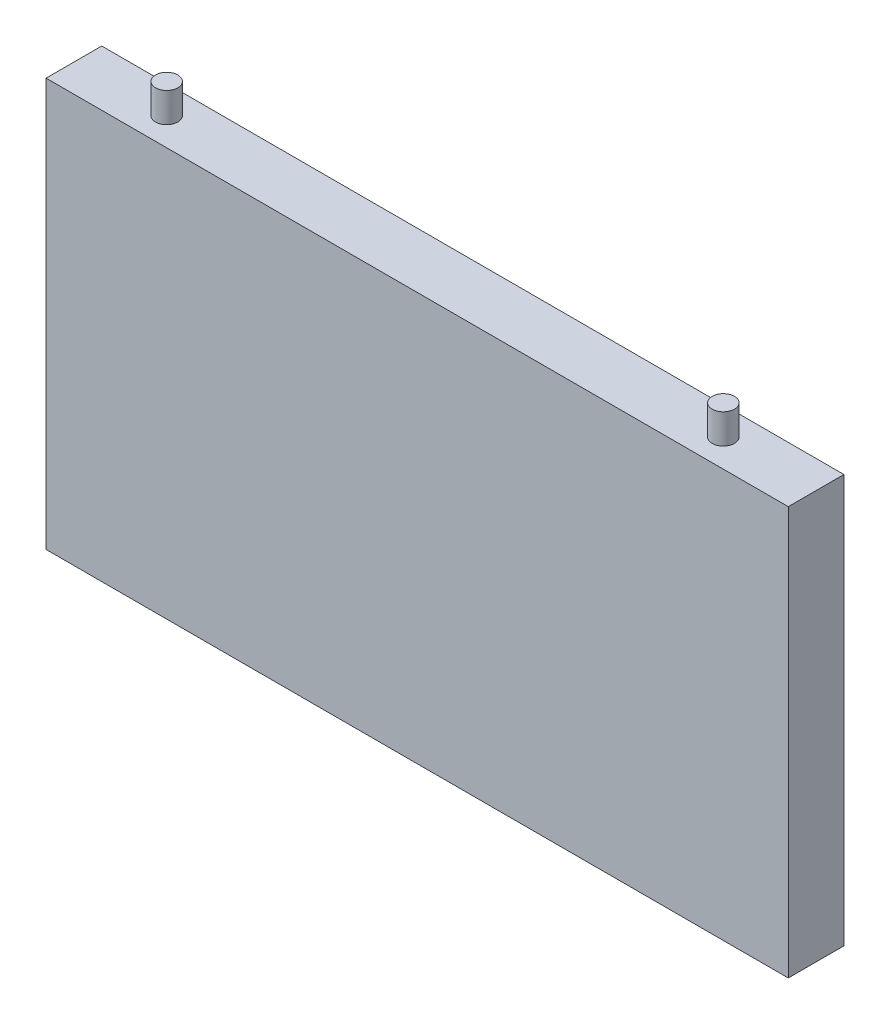
from build123d import *

# Parameters (mm, degrees)
ESBO_O1_W                = 200
ESBO_O1_H                = 110
RESSALTO_EXTRUS_O1_DEPTH = 15
ESBO_O7_R                = 3
RESSALTO_EXTRUS_O2_DEPTH = 8


with BuildPart() as part:
    # Esboço1 → Ressalto-extrusão1 (new body)
    with BuildSketch(Plane.XY):
        with Locations((100, 55)):
            Rectangle(ESBO_O1_W, ESBO_O1_H)
    extrude(amount=RESSALTO_EXTRUS_O1_DEPTH)

    # Esboço7 → Ressalto-extrusão2 (add)
    with BuildSketch(Plane(origin=(0, 110, 0), x_dir=(1, 0, 0), z_dir=(0, 1, 0))):
        with Locations((175, -7.5)):
            Circle(ESBO_O7_R)
        with Locations((25, -7.5)):
            Circle(ESBO_O7_R)
    extrude(amount=RESSALTO_EXTRUS_O2_DEPTH)


solid = part.part
